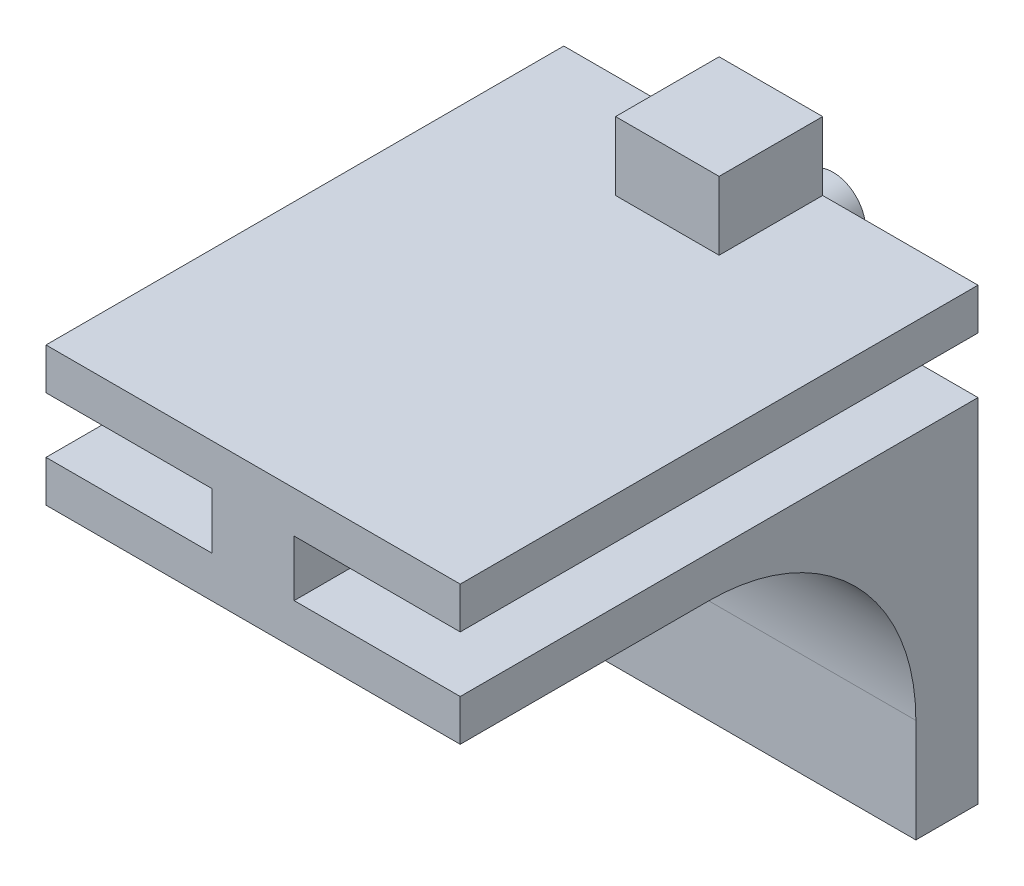
from build123d import *

# Parameters (mm, degrees)
BOSS_EXTRUDE1_DEPTH = 25
SKETCH2_W           = 20
SKETCH2_H           = 3
BOSS_EXTRUDE2_DEPTH = 15
FILLET1_R           = 10
SKETCH3_R           = 1.5748
BOSS_EXTRUDE3_DEPTH = 3
SKETCH4_W           = 5
SKETCH4_H           = 5
BOSS_EXTRUDE4_DEPTH = 3.3


with BuildPart() as part:
    # Sketch1 → Boss-Extrude1 (new body)
    with BuildSketch(Plane.XY):
        Polygon((10, -3.35), (-10, -3.35), (-10, -1.35), (-1.9812, -1.35), (-1.9812, 1.35), (-10, 1.35), (-10, 3.35), (10, 3.35), (10, 1.35), (1.9812, 1.35), (1.9812, -1.35), (10, -1.35), align=None)
    extrude(amount=BOSS_EXTRUDE1_DEPTH)

    # Sketch2 → Boss-Extrude2 (add)
    with BuildSketch(Plane.XZ.offset(3.35)):
        with Locations((0, 1.5)):
            Rectangle(SKETCH2_W, SKETCH2_H)
    extrude(amount=BOSS_EXTRUDE2_DEPTH)

    # Fillet1
    fillet1_edges = [part.edges().sort_by_distance(p)[0] for p in [
        (0, -3.35, 3),
    ]]
    fillet(fillet1_edges, radius=FILLET1_R)

    # Sketch3 → Boss-Extrude3 (add)
    with BuildSketch(Plane(origin=(0, 0, 0), x_dir=(-1, 0, 0), z_dir=(0, 0, -1))):
        Circle(SKETCH3_R)
    extrude(amount=BOSS_EXTRUDE3_DEPTH)

    # Sketch4 → Boss-Extrude4 (add)
    with BuildSketch(Plane(origin=(0, 3.35, 0), x_dir=(1, 0, 0), z_dir=(0, 1, 0))):
        with Locations((0, -2.5)):
            Rectangle(SKETCH4_W, SKETCH4_H)
    extrude(amount=BOSS_EXTRUDE4_DEPTH)


solid = part.part
